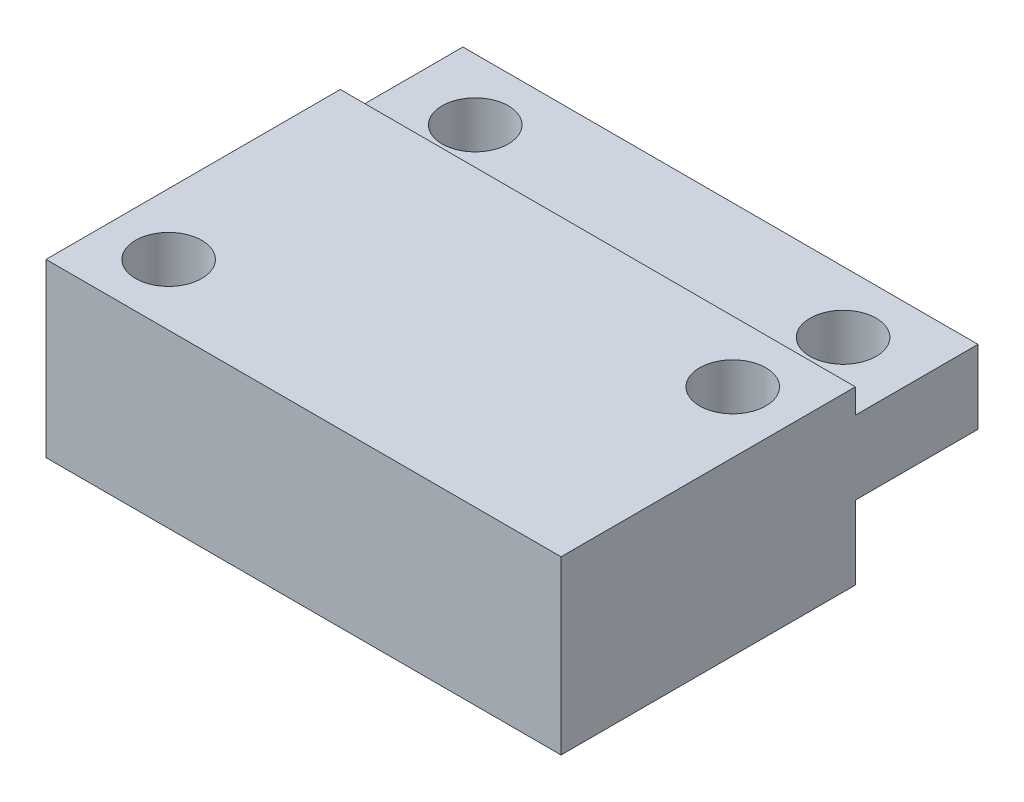
from build123d import *

# Parameters (mm, degrees)
SKETCH1_W              = 21
SKETCH1_H              = 17
BOSS_EXTRUDE1_DEPTH    = 7
SKETCH2_W              = 21
SKETCH2_H              = 5
CUT_EXTRUDE1_DEPTH     = 1
M2_5_CLEARANCE_HOLE1_D = 2.7
SKETCH5_W              = 21
SKETCH5_H              = 5
CUT_EXTRUDE2_DEPTH     = 3
M2_5_CLEARANCE_HOLE2_D = 2.7


with BuildPart() as part:
    # Sketch1 → Boss-Extrude1 (new body)
    with BuildSketch(Plane(origin=(0, 0, 0), x_dir=(1, 0, 0), z_dir=(0, 1, 0))):
        Rectangle(SKETCH1_W, SKETCH1_H)
    extrude(amount=BOSS_EXTRUDE1_DEPTH)

    # Sketch2 → Cut-Extrude1 (cut)
    with BuildSketch(Plane(origin=(0, 7, 0), x_dir=(1, 0, 0), z_dir=(0, 1, 0))):
        with Locations((0, 6)):
            Rectangle(SKETCH2_W, SKETCH2_H)
    extrude(amount=-CUT_EXTRUDE1_DEPTH, mode=Mode.SUBTRACT)

    # M2.5 Clearance Hole1 (through all)
    with Locations(Plane(origin=(0, 7, 0), x_dir=(1, 0, 0), z_dir=(0, 1, 0))):
        with Locations((-8, -6), (8, 1)):
            Hole(M2_5_CLEARANCE_HOLE1_D / 2)

    # Sketch5 → Cut-Extrude2 (cut)
    with BuildSketch(Plane.XZ):
        with Locations((0, -6)):
            Rectangle(SKETCH5_W, SKETCH5_H)
    extrude(amount=-CUT_EXTRUDE2_DEPTH, mode=Mode.SUBTRACT)

    # M2.5 Clearance Hole2 (through all)
    with Locations(Plane(origin=(0, 3, 0), x_dir=(-1, 0, 0), z_dir=(0, -1, 0))):
        with Locations((-7.5, 6), (7.5, 6)):
            Hole(M2_5_CLEARANCE_HOLE2_D / 2)


solid = part.part
